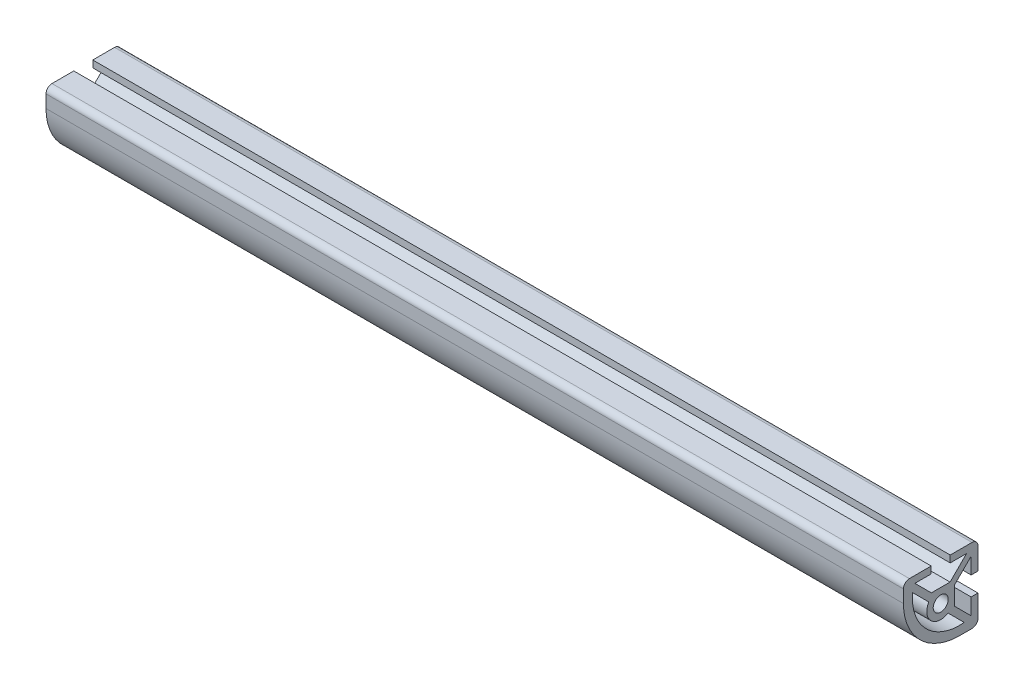
from build123d import *

# Parameters (mm, degrees)
SKETCH3_R                = 2.5527
BOSS_EXTRUDE1_DEPTH      = 146.05
BOSS_EXTRUDE1_DEPTH_BACK = 146.05


with BuildPart() as part:
    # Sketch3 → Boss-Extrude1 (new body, two sides)
    with BuildSketch(Plane(origin=(0, 0, 0), x_dir=(0, 0, -1), z_dir=(1, 0, 0))) as boss_extrude1_sk:
        with BuildLine():
            Line((-10.668, 12.7), (-3.2385, 12.7))
            Line((-3.2385, 12.7), (-3.2385, 10.3632))
            Line((-3.2385, 10.3632), (-8.800635435, 10.3632))
            Line((-8.800635435, 10.3632), (-3.187235669, 4.749800235))
            Line((-3.187235669, 4.749800235), (3.187235669, 4.749800235))
            Line((3.187235669, 4.749800235), (8.800635435, 10.3632))
            Line((8.800635435, 10.3632), (3.2385, 10.3632))
            Line((3.2385, 10.3632), (3.2385, 12.7))
            Line((3.2385, 12.7), (10.668, 12.7))
            ThreePointArc((10.668, 12.7), (12.104840979, 12.104840979), (12.7, 10.668))
            Line((12.7, 10.668), (12.7, 3.2385))
            Line((12.7, 3.2385), (10.3632, 3.2385))
            Line((10.3632, 3.2385), (10.3632, 8.800635435))
            Line((10.3632, 8.800635435), (4.749800235, 3.187235669))
            Line((4.749800235, 3.187235669), (4.749800235, -3.187235669))
            Line((4.749800235, -3.187235669), (10.3632, -8.800635435))
            Line((10.3632, -8.800635435), (10.3632, -3.2385))
            Line((10.3632, -3.2385), (12.7, -3.2385))
            Line((12.7, -3.2385), (12.7, -10.668))
            ThreePointArc((12.7, -10.668), (12.104840979, -12.104840979), (10.668, -12.7))
            Line((10.668, -12.7), (6.35, -12.7))
            ThreePointArc((6.35, -12.7), (-7.120384182, -7.120384182), (-12.7, 6.35))
            Line((-12.7, 6.35), (-12.7, 10.668))
            ThreePointArc((-12.7, 10.668), (-12.104840979, 12.104840979), (-10.668, 12.7))
        make_face()
        Circle(SKETCH3_R, mode=Mode.SUBTRACT)
        with BuildLine():
            Line((2.485198871, -4.047763436), (8.003751298, -9.566315863))
            ThreePointArc((8.003751298, -9.566315863), (-4.965122713, -4.965122713), (-9.566315863, 8.003751298))
            Line((-9.566315863, 8.003751298), (-4.047763436, 2.485198871))
            ThreePointArc((-4.047763436, 2.485198871), (-3.358615955, -3.358615955), (2.485198871, -4.047763436))
        make_face(mode=Mode.SUBTRACT)
    extrude(amount=BOSS_EXTRUDE1_DEPTH)
    extrude(boss_extrude1_sk.sketch, amount=-BOSS_EXTRUDE1_DEPTH_BACK)


solid = part.part
